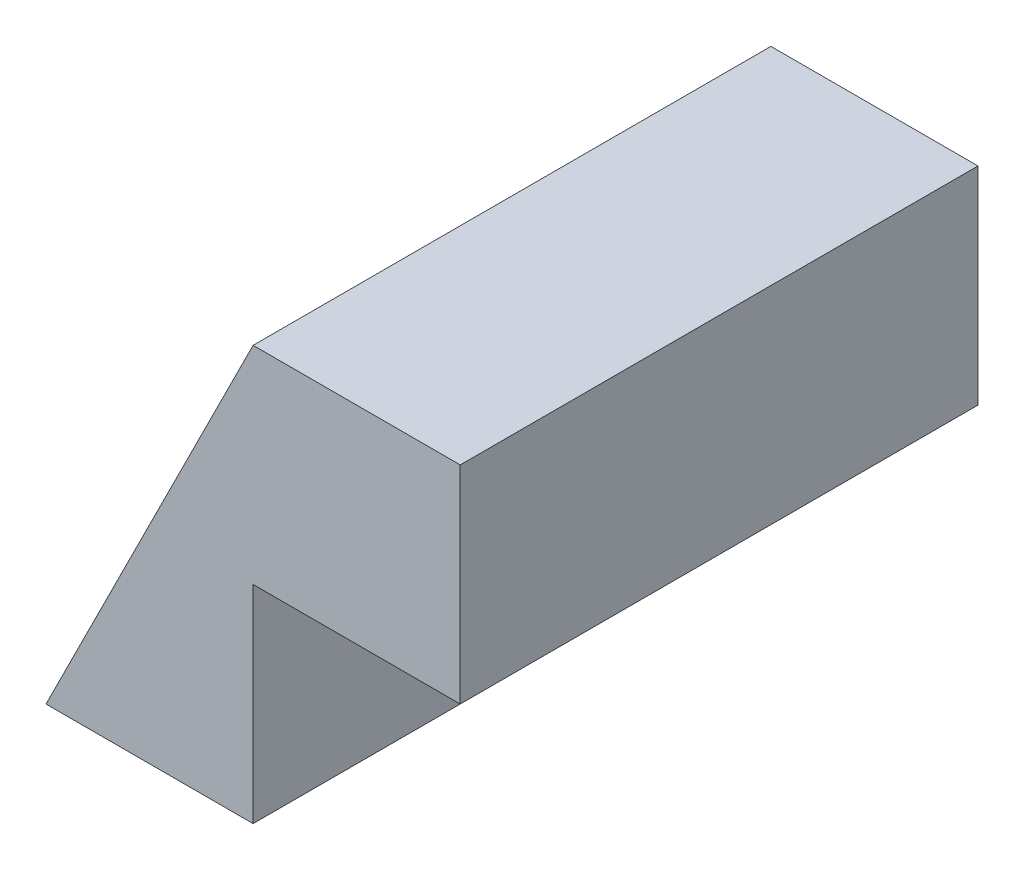
from build123d import *

# Parameters (mm, degrees)
BOSS_EXTRUDE1_DEPTH = 25


with BuildPart() as part:
    # Sketch1 → Boss-Extrude1 (new body)
    with BuildSketch(Plane.XY):
        Polygon((-20, -10), (-10, 10), (0, 10), (0, 0), (-10, 0), (-10, -10), align=None)
    extrude(amount=BOSS_EXTRUDE1_DEPTH)


solid = part.part
